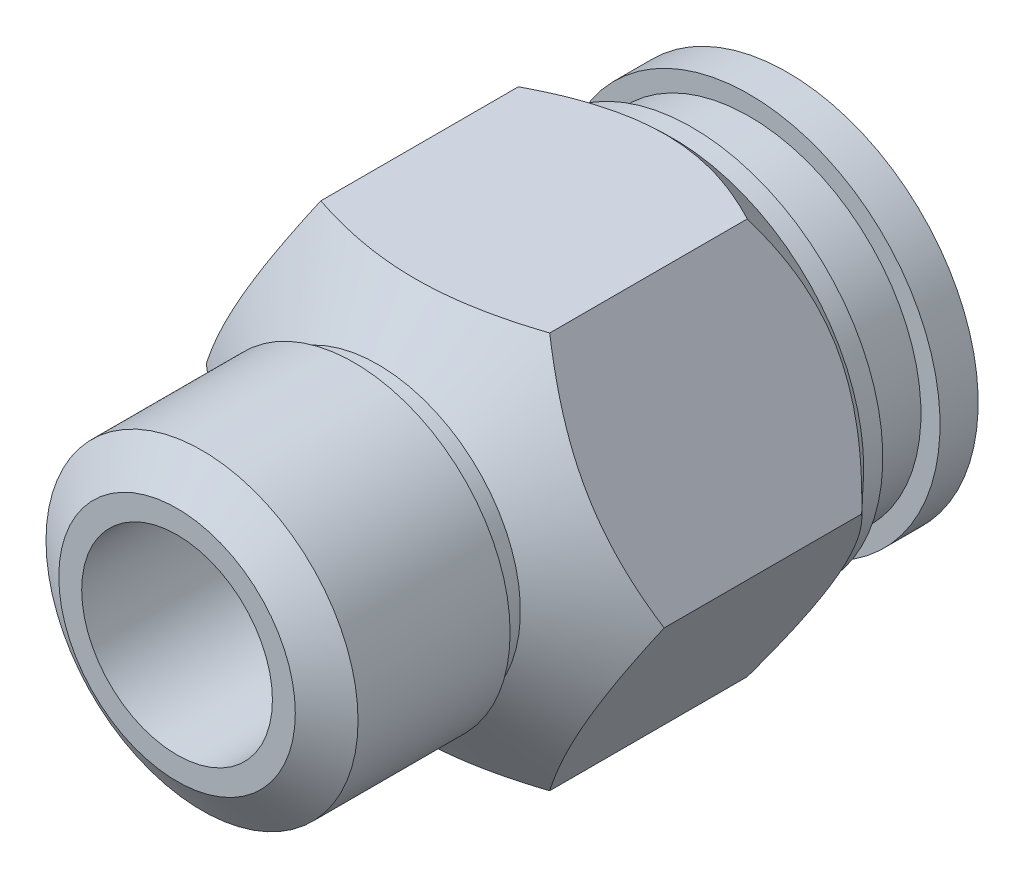
from build123d import *

# Parameters (mm, degrees)
CROQUIS2_OUTSIDE_W    = 35.33
CROQUIS2_OUTSIDE_H    = 35.33
CORTAR_EXTRUIR2_DEPTH = 40


with BuildPart() as part:
    # Croquis1 → Revolución1 (revolve)
    with BuildSketch(Plane(origin=(0, 0, 0), x_dir=(1, 0, 0), z_dir=(0, 1, 0))):
        Polygon((5, 26.679286354), (10, 26.679286354), (10, 24.679286354), (9, 24.679286354), (9, 21.679286354), (10, 21.679286354), (10, 20.679286354), (12, 18.574849316), (12, 8.21549426), (7.464345365, 5.21549426), (7.464345365, 4.439385), (8.179362134, 3.961906928), (8.179362134, -4.011582493), (6.20010654, -5.320713646), (5, -5.320713646), align=None)
    revolve(axis=Axis((0, 0, -34.95637535), (0, 0, 1)))

    # Croquis2 outside → Cortar-Extruir2 (cut)
    with BuildSketch(Plane.XY):
        Rectangle(CROQUIS2_OUTSIDE_W, CROQUIS2_OUTSIDE_H)
        Polygon((12, 0), (6, 10.392304845), (-6, 10.392304845), (-12, 0), (-6, -10.392304845), (6, -10.392304845), align=None, mode=Mode.SUBTRACT)
    extrude(amount=-CORTAR_EXTRUIR2_DEPTH, mode=Mode.SUBTRACT)


solid = part.part
